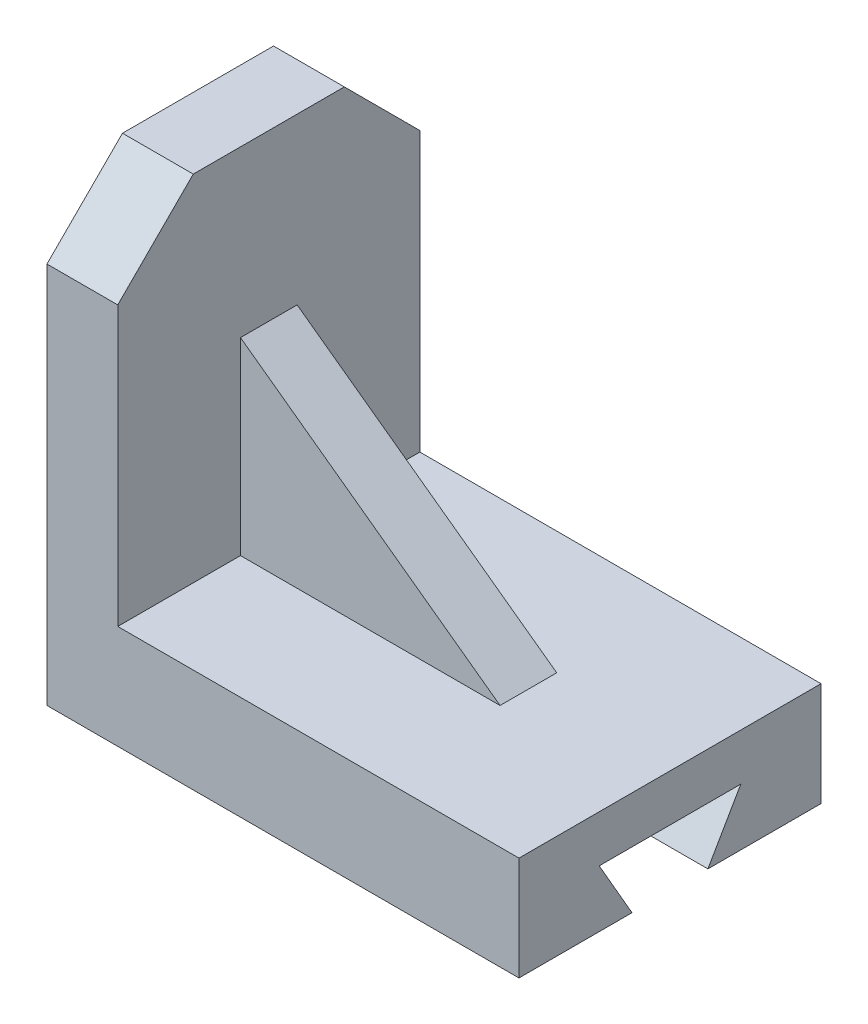
from build123d import *

# Parameters (mm, degrees)
SKETCH2_W           = 100
SKETCH2_H           = 64
BOSS_EXTRUDE1_DEPTH = 22
CUT_EXTRUDE1_DEPTH  = 126
SKETCH4_W           = 15
SKETCH4_H           = 64
BOSS_EXTRUDE2_DEPTH = 75
CHAMFER1_SIZE       = 16
CHAMFER2_SIZE       = 16
RIB2_REACH          = 128.044
SKETCH10_WALL_W     = 322.09589175
SKETCH10_WALL_H     = 12


with BuildPart() as part:
    # Sketch2 → Boss-Extrude1 (new body)
    with BuildSketch(Plane(origin=(0, 0, 0), x_dir=(1, 0, 0), z_dir=(0, 1, 0))):
        with Locations((-23.852270783, -4.169452289)):
            Rectangle(SKETCH2_W, SKETCH2_H)
    extrude(amount=BOSS_EXTRUDE1_DEPTH)

    # Sketch3 → Cut-Extrude1 (cut)
    with BuildSketch(Plane.ZY.offset(73.852270783)):
        Polygon((19.169452289, 12.073281473), (12.217656655, 0), (-3.860035403, 0), (-10.830547711, 12.073281473), align=None)
    extrude(amount=-CUT_EXTRUDE1_DEPTH, mode=Mode.SUBTRACT)

    # Sketch4 → Boss-Extrude2 (add)
    with BuildSketch(Plane(origin=(0, 22, 0), x_dir=(1, 0, 0), z_dir=(0, 1, 0))):
        with Locations((-66.352270783, -4.169452289)):
            Rectangle(SKETCH4_W, SKETCH4_H)
    extrude(amount=BOSS_EXTRUDE2_DEPTH)

    # Chamfer1
    chamfer1_edges = [part.edges().sort_by_distance(p)[0] for p in [
        (-66.352270783, 97, 36.169452289),
    ]]
    chamfer(chamfer1_edges, length=CHAMFER1_SIZE)

    # Chamfer2
    chamfer2_edges = [part.edges().sort_by_distance(p)[0] for p in [
        (-66.352270783, 97, -27.830547711),
    ]]
    chamfer(chamfer2_edges, length=CHAMFER2_SIZE)

    # Sketch10 wall → Rib2 (add, up to next)
    with BuildSketch(Plane(origin=(-31.352270783, 42, 4.169452289), x_dir=(0.808736084303, -0.588171697675, 0), z_dir=(0.588171697675, 0.808736084303, 0)), mode=Mode.PRIVATE) as rib2_sk1:
        Rectangle(SKETCH10_WALL_W, SKETCH10_WALL_H)
    rib2_tool1 = extrude(rib2_sk1.sketch, amount=-RIB2_REACH, mode=Mode.PRIVATE) - part.part
    add(rib2_tool1.solids().sort_by_distance((-31.352270783, 42, 4.169452289))[0])


solid = part.part
